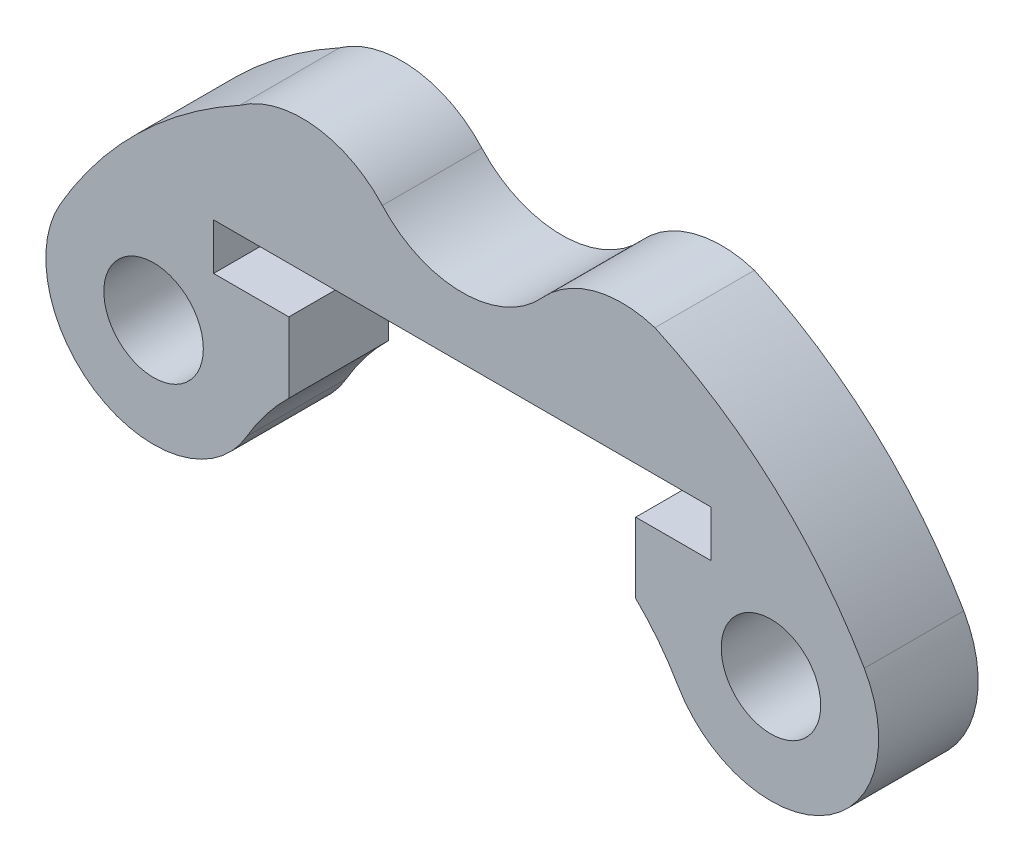
from build123d import *

# Parameters (mm, degrees)
ESQUISSE1_R        = 1.5
BOSS_EXTRU_2_DEPTH = 3


with BuildPart() as part:
    # Esquisse1 → Boss.-Extru.2 (new body)
    with BuildSketch(Plane.XY):
        with BuildLine():
            Line((5.230618988, 7.5), (7.5, 7.5))
            Line((7.5, 7.5), (7.5, 8.9))
            Line((7.5, 8.9), (-7.5, 8.9))
            Line((-7.5, 8.9), (-7.5, 7.5))
            Line((-7.5, 7.5), (-5.230618988, 7.5))
            Line((-5.230618988, 7.5), (-5.230618988, 5.375))
            ThreePointArc((-5.230618988, 5.375), (-5.918936429, 4.606103727), (-6.495190528, 3.75))
            ThreePointArc((-6.495190528, 3.75), (-10.934773091, 2.560417438), (-12.124355653, 7))
            ThreePointArc((-12.124355653, 7), (-9.780131311, 10.017436376), (-6.707371512, 12.288660114))
            ThreePointArc((-6.707371512, 12.288660114), (-4.47014813, 12.872261577), (-2.411034891, 11.820685714))
            ThreePointArc((-2.411034891, 11.820685714), (0, 10.75), (2.411034891, 11.820685714))
            ThreePointArc((2.411034891, 11.820685714), (3.975330286, 12.779130538), (5.80943088, 12.737759334))
            ThreePointArc((5.80943088, 12.737759334), (9.414650572, 10.36167721), (12.124355653, 7))
            ThreePointArc((12.124355653, 7), (10.934773091, 2.560417438), (6.495190528, 3.75))
            ThreePointArc((6.495190528, 3.75), (5.918936429, 4.606103727), (5.230618988, 5.375))
            Line((5.230618988, 5.375), (5.230618988, 7.5))
        make_face()
        with Locations((9.309773091, 5.375)):
            Circle(ESQUISSE1_R, mode=Mode.SUBTRACT)
        with Locations((-9.309773091, 5.375)):
            Circle(ESQUISSE1_R, mode=Mode.SUBTRACT)
    extrude(amount=BOSS_EXTRU_2_DEPTH)


solid = part.part
